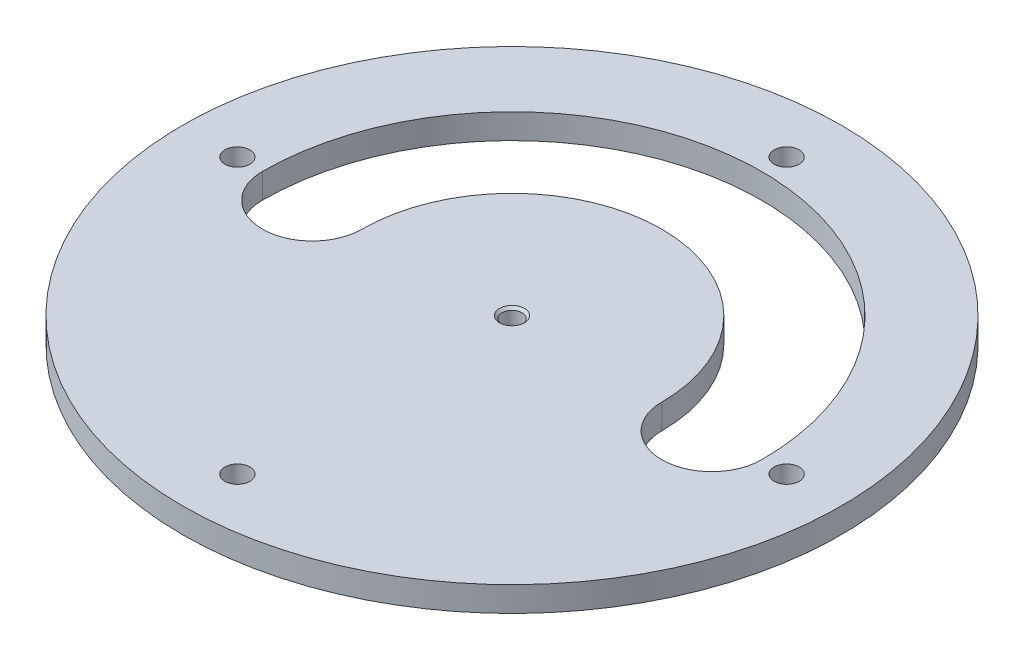
from build123d import *

# Parameters (mm, degrees)
SKETCH1_R               = 33
SKETCH1_R_2             = 1.25
SKETCH1_R_3             = 1
BOSS_EXTRUDE2_DEPTH     = 2.5
CUT_EXTRUDE1_DEPTH      = 3.5
CUT_EXTRUDE1_DEPTH_BACK = 10
CHAMFER5_SIZE           = 0.25


with BuildPart() as part:
    # Sketch1 → Boss-Extrude2 (new body)
    with BuildSketch(Plane(origin=(0, 0, 0), x_dir=(1, 0, 0), z_dir=(0, 1, 0))):
        Circle(SKETCH1_R)
        with Locations((0, 27.5)):
            Circle(SKETCH1_R_2, mode=Mode.SUBTRACT)
        with Locations((27.5, 0)):
            Circle(SKETCH1_R_2, mode=Mode.SUBTRACT)
        with Locations((0, -27.5)):
            Circle(SKETCH1_R_2, mode=Mode.SUBTRACT)
        with Locations((-27.5, 0)):
            Circle(SKETCH1_R_2, mode=Mode.SUBTRACT)
        Circle(SKETCH1_R_3, mode=Mode.SUBTRACT)
    extrude(amount=BOSS_EXTRUDE2_DEPTH)

    # Sketch2 → Cut-Extrude1 (cut, two sides)
    with BuildSketch(Plane(origin=(0, 0, 0), x_dir=(1, 0, 0), z_dir=(0, 1, 0))) as cut_extrude1_sk:
        with BuildLine():
            ThreePointArc((25, 0), (0, 25), (-25, 0))
            ThreePointArc((-25, 0), (-20, -5), (-15, 0))
            ThreePointArc((-15, 0), (0, 15), (15, 0))
            ThreePointArc((15, 0), (20, -5), (25, 0))
        make_face()
    extrude(amount=CUT_EXTRUDE1_DEPTH, mode=Mode.SUBTRACT)
    extrude(cut_extrude1_sk.sketch, amount=-CUT_EXTRUDE1_DEPTH_BACK, mode=Mode.SUBTRACT)

    # Chamfer5
    chamfer5_edges = [part.edges().sort_by_distance(p)[0] for p in [
        (-1, 2.5, 0),
    ]]
    chamfer(chamfer5_edges, length=CHAMFER5_SIZE)


solid = part.part
